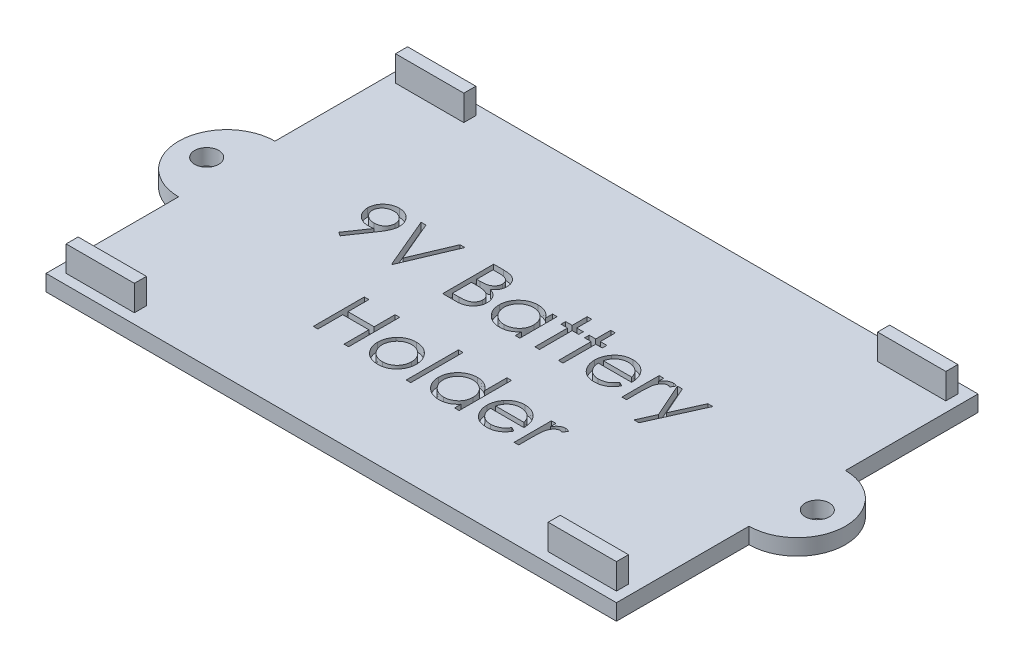
from build123d import *

# Parameters (mm, degrees)
SKETCH1_W               = 71
SKETCH1_H               = 45
BOSS_EXTRUDE1_DEPTH     = 2
SKETCH2_W               = 8.5
SKETCH2_H               = 1.5
BOSS_EXTRUDE2_DEPTH     = 3.175
MIRROR2_COPY_1_SKETCH_W = 8.5
MIRROR2_COPY_1_SKETCH_H = 1.5
MIRROR2_COPY_1_DEPTH    = 3.175
SKETCH3_W               = 0.569871795
SKETCH3_H               = 6.512820512
CUT_EXTRUDE1_DEPTH      = 1
BOSS_EXTRUDE3_DEPTH     = 2
SKETCH5_R               = 1.5
CUT_EXTRUDE2_DEPTH      = 2


with BuildPart() as part:
    # Sketch1 → Boss-Extrude1 (new body)
    with BuildSketch(Plane(origin=(0, 0, 0), x_dir=(1, 0, 0), z_dir=(0, 1, 0))):
        Rectangle(SKETCH1_W, SKETCH1_H)
    extrude(amount=BOSS_EXTRUDE1_DEPTH)

    # Sketch2 → Boss-Extrude2 (add)
    with BuildSketch(Plane(origin=(0, 2, 0), x_dir=(1, 0, 0), z_dir=(0, 1, 0))):
        with Locations((-30, -20.5)):
            Rectangle(SKETCH2_W, SKETCH2_H)
    boss_extrude2 = extrude(amount=BOSS_EXTRUDE2_DEPTH)

    # Mirror1: Boss-Extrude2 across plane
    add(boss_extrude2.mirror(Plane.XY))

    # Mirror2: Boss-Extrude2 across plane
    add(boss_extrude2.mirror(Plane(origin=(0, 0, 0), x_dir=(0, 0, 1), z_dir=(1, 0, 0))))

    # Mirror2 copy 1 sketch → Mirror2 copy 1 (add)
    with BuildSketch(Plane(origin=(0, 2, 0), x_dir=(-1, 0, 0), z_dir=(0, 1, 0))):
        with Locations((-30, -20.5)):
            Rectangle(MIRROR2_COPY_1_SKETCH_W, MIRROR2_COPY_1_SKETCH_H)
    extrude(amount=MIRROR2_COPY_1_DEPTH)

    # Sketch3 → Cut-Extrude1 (cut)
    with BuildSketch(Plane(origin=(0, 2, 0), x_dir=(1, 0, 0), z_dir=(0, 1, 0))):
        with BuildLine():
            Line((-21.248076923, -0.162820513), (-21.703465545, 0.153916266))
            Line((-21.703465545, 0.153916266), (-19.937880609, 2.734875801))
            add(Edge.make_bspline(
                [(-19.937880609, 2.734875801), (-20.050530944, 2.721099815), (-20.272345733, 2.69397413), (-20.495751618, 2.688990913), (-20.605699119, 2.686538462)],
                knots=[0, 0, 0, 0, 0.000340231, 0.000669933, 0.000669933, 0.000669933, 0.000669933], degree=3))
            add(Edge.make_bspline(
                [(-20.605699119, 2.686538462), (-20.672359691, 2.688245843), (-20.803208565, 2.691597284), (-20.995580278, 2.718161707), (-21.180429795, 2.759074082), (-21.357267055, 2.820122538), (-21.526756728, 2.895992717), (-21.688528808, 2.990076156), (-21.842365524, 3.100758999), (-21.986614682, 3.227455998), (-22.117808837, 3.366571893), (-22.234691105, 3.513811417), (-22.331830016, 3.670884964), (-22.41252325, 3.834588362), (-22.47371993, 4.007274527), (-22.518283391, 4.186978439), (-22.545719662, 4.374959561), (-22.548983736, 4.502912298), (-22.550641026, 4.567878606)],
                knots=[0, 0, 0, 0, 0.000199908, 0.000392402, 0.000581563, 0.000767006, 0.000952605, 0.001137838, 0.00132741, 0.001520307, 0.001712868, 0.00190041, 0.002083247, 0.002265863, 0.002446921, 0.002631721, 0.002820609, 0.003015434, 0.003015434, 0.003015434, 0.003015434], degree=3))
            add(Edge.make_bspline(
                [(-22.550641026, 4.567878606), (-22.547494265, 4.656721733), (-22.541317813, 4.831102769), (-22.491609075, 5.08588975), (-22.409856745, 5.326802479), (-22.295868119, 5.553207545), (-22.152295124, 5.761848115), (-21.979740968, 5.949823734), (-21.779255204, 6.114460826), (-21.555404969, 6.255982509), (-21.313464489, 6.369801719), (-21.060065638, 6.453693021), (-20.79715002, 6.503039321), (-20.619045818, 6.509545097), (-20.529377003, 6.512820513)],
                knots=[0, 0, 0, 0, 0.000266369, 0.000522829, 0.000775449, 0.001027459, 0.001280799, 0.00153288, 0.001790375, 0.002056814, 0.002325395, 0.002590482, 0.002855691, 0.0031246, 0.0031246, 0.0031246, 0.0031246], degree=3))
            add(Edge.make_bspline(
                [(-20.529377003, 6.512820513), (-20.441405156, 6.509500074), (-20.267581078, 6.5029392), (-20.011968167, 6.454889713), (-19.767146607, 6.373906036), (-19.53447356, 6.261992613), (-19.319046341, 6.121710395), (-19.125324512, 5.954552044), (-18.957728891, 5.760413445), (-18.816534136, 5.543990042), (-18.703195634, 5.311458519), (-18.621421635, 5.068736259), (-18.571083118, 4.817568865), (-18.564739782, 4.64739889), (-18.561538462, 4.561518429)],
                knots=[0, 0, 0, 0, 0.00026383, 0.000521303, 0.000777137, 0.001035436, 0.001293696, 0.001546188, 0.001800474, 0.002060496, 0.002319348, 0.002574378, 0.002827091, 0.003084573, 0.003084573, 0.003084573, 0.003084573], degree=3))
            add(Edge.make_bspline(
                [(-18.561538462, 4.561518429), (-18.563676432, 4.494854738), (-18.56801277, 4.359644114), (-18.598377213, 4.15421192), (-18.649939549, 3.944750404), (-18.708453345, 3.767455509), (-18.764935993, 3.621027322), (-18.818096617, 3.505363741), (-18.877082953, 3.383622877), (-18.945878427, 3.257081278), (-19.01983288, 3.124125822), (-19.103397567, 2.986090038), (-19.194666248, 2.842788693), (-19.259671596, 2.746183262), (-19.292958734, 2.696714744)],
                knots=[0, 0, 0, 0, 0.000199969, 0.000405586, 0.000621552, 0.000846414, 0.000965232, 0.001092194, 0.001228159, 0.001371001, 0.001524206, 0.001684548, 0.001854987, 0.002033856, 0.002033856, 0.002033856, 0.002033856], degree=3))
            Line((-19.292958734, 2.696714744), (-21.248076923, -0.162820513))
        make_face()
        with BuildLine():
            add(Edge.make_bspline(
                [(-20.500120192, 3.337820513), (-20.449621338, 3.339200066), (-20.351317237, 3.341885588), (-20.207304137, 3.358230927), (-20.071370225, 3.387212301), (-19.943152387, 3.428795208), (-19.821365008, 3.478972307), (-19.707942527, 3.54285691), (-19.602790019, 3.619087091), (-19.505203351, 3.704739548), (-19.418545809, 3.799899892), (-19.341360596, 3.899498928), (-19.275754995, 4.003973864), (-19.223933049, 4.114633068), (-19.18132532, 4.228782861), (-19.151901212, 4.348261477), (-19.135601065, 4.472446432), (-19.13282235, 4.556808283), (-19.131410256, 4.599679487)],
                knots=[0, 0, 0, 0, 0.000151506, 0.00029493, 0.000434147, 0.000567705, 0.000698823, 0.000828676, 0.000957177, 0.001087851, 0.001217486, 0.001342663, 0.001465499, 0.00158669, 0.001708626, 0.00183049, 0.00195498, 0.002083613, 0.002083613, 0.002083613, 0.002083613], degree=3))
            add(Edge.make_bspline(
                [(-19.131410256, 4.599679487), (-19.132625228, 4.642568594), (-19.135019477, 4.72708684), (-19.154227864, 4.851455654), (-19.18801934, 4.970641998), (-19.23335922, 5.085298378), (-19.293085937, 5.194482767), (-19.364756547, 5.299565963), (-19.44990542, 5.399881681), (-19.547881504, 5.493070623), (-19.653535622, 5.57897324), (-19.766131101, 5.65478512), (-19.884739877, 5.718323577), (-20.008638337, 5.770754565), (-20.138084627, 5.811669929), (-20.273002149, 5.841092862), (-20.41407267, 5.857370189), (-20.509833004, 5.86013134), (-20.558633814, 5.861538462)],
                knots=[0, 0, 0, 0, 0.000128633, 0.000253487, 0.000376322, 0.000499624, 0.000622565, 0.000748875, 0.00088064, 0.001016486, 0.00115396, 0.00128873, 0.001423042, 0.001556999, 0.001691769, 0.001829742, 0.00197064, 0.002117062, 0.002117062, 0.002117062, 0.002117062], degree=3))
            add(Edge.make_bspline(
                [(-20.558633814, 5.861538462), (-20.607010207, 5.860129067), (-20.70192429, 5.857363846), (-20.841740694, 5.841123803), (-20.975745956, 5.811472053), (-21.104817181, 5.770773517), (-21.22871196, 5.718319666), (-21.347315142, 5.654781791), (-21.459936958, 5.578990691), (-21.56548978, 5.493003032), (-21.663638867, 5.400315446), (-21.747323755, 5.29912651), (-21.819158388, 5.19453743), (-21.878803036, 5.085283851), (-21.924164746, 4.970645876), (-21.957950377, 4.851454604), (-21.977160334, 4.727087114), (-21.979554369, 4.642568686), (-21.980769231, 4.599679487)],
                knots=[0, 0, 0, 0, 0.000145151, 0.000284786, 0.000421516, 0.000556286, 0.000690243, 0.000824556, 0.000959325, 0.001096799, 0.001232645, 0.001363591, 0.001489901, 0.001612842, 0.001736144, 0.001858979, 0.001983833, 0.002112466, 0.002112466, 0.002112466, 0.002112466], degree=3))
            add(Edge.make_bspline(
                [(-21.980769231, 4.599679487), (-21.979669908, 4.556774898), (-21.977501841, 4.472159196), (-21.956587137, 4.34783274), (-21.921610829, 4.228655588), (-21.874767078, 4.113468934), (-21.813078479, 4.003392848), (-21.737379497, 3.898949206), (-21.648650864, 3.798954032), (-21.548078679, 3.704960948), (-21.438009301, 3.618687715), (-21.320449491, 3.543339736), (-21.197423072, 3.479708301), (-21.068496971, 3.42865179), (-20.934626634, 3.387627772), (-20.794608895, 3.35828434), (-20.648906807, 3.342042371), (-20.550191555, 3.3392413), (-20.500120192, 3.337820513)],
                knots=[0, 0, 0, 0, 0.000128633, 0.000253688, 0.000376872, 0.000500652, 0.000625933, 0.000754433, 0.000886902, 0.001026392, 0.001166853, 0.001305877, 0.001444692, 0.001581695, 0.001721324, 0.001864273, 0.002010225, 0.00216046, 0.00216046, 0.00216046, 0.00216046], degree=3))
        make_face(mode=Mode.SUBTRACT)
        Polygon((-17.666025641, 6.35), (-17.055448718, 6.35), (-14.938782051, 1.345813301), (-12.822115385, 6.35), (-12.211538462, 6.35), (-14.898076923, 0), (-14.979487179, 0), align=None)
        with BuildLine():
            Line((-8.629487179, 6.35), (-7.39052484, 6.35))
            add(Edge.make_bspline(
                [(-7.39052484, 6.35), (-7.329876029, 6.349681139), (-7.212323541, 6.349063106), (-7.041382553, 6.339477996), (-6.881273997, 6.326408481), (-6.731951438, 6.305671027), (-6.593483878, 6.280648803), (-6.465454022, 6.250346937), (-6.348268995, 6.214012938), (-6.208364459, 6.156234684), (-6.04885126, 6.070376936), (-5.876134176, 5.943506539), (-5.728443628, 5.788326213), (-5.601105595, 5.61327911), (-5.499866421, 5.420718496), (-5.426624982, 5.215233967), (-5.380255693, 4.99947595), (-5.375486963, 4.851351899), (-5.373076923, 4.776492388)],
                knots=[0, 0, 0, 0, 0.000181919, 0.000352604, 0.00051349, 0.000663703, 0.00080467, 0.000935486, 0.001058189, 0.001172283, 0.001389131, 0.001600035, 0.00181234, 0.002029124, 0.002247618, 0.002462475, 0.002682011, 0.002906326, 0.002906326, 0.002906326, 0.002906326], degree=3))
            add(Edge.make_bspline(
                [(-5.373076923, 4.776492388), (-5.375060334, 4.706365608), (-5.378957923, 4.568559873), (-5.416228357, 4.367003418), (-5.474576999, 4.175140492), (-5.555685094, 3.993671307), (-5.661098715, 3.826696038), (-5.786027379, 3.672867712), (-5.936752435, 3.538699366), (-6.049679456, 3.463691528), (-6.107041266, 3.425590946)],
                knots=[0, 0, 0, 0, 0.000210198, 0.000413059, 0.000612634, 0.000810762, 0.001007352, 0.001203448, 0.00140342, 0.001609859, 0.001609859, 0.001609859, 0.001609859], degree=3))
            add(Edge.make_bspline(
                [(-6.107041266, 3.425590946), (-6.03490449, 3.397895876), (-5.896888969, 3.344908347), (-5.706958632, 3.251226863), (-5.543319413, 3.149332748), (-5.404713162, 3.038059249), (-5.286171988, 2.918118978), (-5.182661652, 2.78775327), (-5.09433973, 2.645261524), (-5.018660569, 2.492129396), (-4.959607826, 2.329920517), (-4.91538297, 2.160156395), (-4.890042027, 1.983445773), (-4.886435878, 1.863185156), (-4.884615385, 1.802473958)],
                knots=[0, 0, 0, 0, 0.000231723, 0.000443344, 0.000634273, 0.000808894, 0.000975297, 0.001139193, 0.001307198, 0.001477294, 0.001650744, 0.001824133, 0.002002767, 0.002184886, 0.002184886, 0.002184886, 0.002184886], degree=3))
            add(Edge.make_bspline(
                [(-4.884615385, 1.802473958), (-4.886387662, 1.74048549), (-4.889874669, 1.618521443), (-4.915601189, 1.439351413), (-4.959160569, 1.268128296), (-5.019161077, 1.103744607), (-5.097469848, 0.946518363), (-5.192770583, 0.796271441), (-5.306402134, 0.654513441), (-5.433516197, 0.519669154), (-5.577320375, 0.398424454), (-5.732470387, 0.290445958), (-5.900920139, 0.201643816), (-6.079903043, 0.127047606), (-6.271426873, 0.070065974), (-6.474631604, 0.030201447), (-6.68934198, 0.00334088), (-6.836679671, 0.001132523), (-6.912239583, 0)],
                knots=[0, 0, 0, 0, 0.00018593, 0.000365823, 0.000541677, 0.000715127, 0.000889772, 0.001067625, 0.00124781, 0.001434053, 0.001622662, 0.001811078, 0.002000013, 0.002192776, 0.002391982, 0.002598291, 0.002813502, 0.003040053, 0.003040053, 0.003040053, 0.003040053], degree=3))
            Line((-6.912239583, 0), (-8.629487179, 0))
            Line((-8.629487179, 0), (-8.629487179, 6.35))
        make_face()
        with BuildLine():
            Line((-8.059615385, 5.698717949), (-8.059615385, 3.663461538))
            Line((-8.059615385, 3.663461538), (-7.676732772, 3.663461538))
            add(Edge.make_bspline(
                [(-7.676732772, 3.663461538), (-7.620764244, 3.664187113), (-7.51262164, 3.665589071), (-7.356012685, 3.669605023), (-7.210643009, 3.680850045), (-7.076763541, 3.692091835), (-6.954585107, 3.710370015), (-6.844378387, 3.732127153), (-6.744413789, 3.755137566), (-6.6291349, 3.794270778), (-6.498373979, 3.852105989), (-6.358976776, 3.941862034), (-6.236087095, 4.048767646), (-6.132315054, 4.172122677), (-6.047385672, 4.307951329), (-5.988396503, 4.454086383), (-5.948396431, 4.606885765), (-5.944783224, 4.711784596), (-5.942948718, 4.765044071)],
                knots=[0, 0, 0, 0, 0.000167928, 0.000324471, 0.00046984, 0.000605274, 0.000727423, 0.000840183, 0.000942303, 0.001034821, 0.00120505, 0.001369832, 0.0015303, 0.001691868, 0.001851786, 0.002008639, 0.002163205, 0.002322621, 0.002322621, 0.002322621, 0.002322621], degree=3))
            add(Edge.make_bspline(
                [(-5.942948718, 4.765044071), (-5.943903359, 4.80028797), (-5.945775992, 4.869422728), (-5.961112698, 4.970205128), (-5.987179583, 5.064990222), (-6.020660944, 5.155076965), (-6.067448993, 5.237648464), (-6.122536991, 5.315559691), (-6.189095315, 5.386157392), (-6.264855011, 5.452142053), (-6.351956369, 5.510642839), (-6.450347427, 5.561879652), (-6.561359356, 5.603137918), (-6.68312125, 5.639271509), (-6.817507366, 5.664650271), (-6.962966913, 5.685792846), (-7.120691331, 5.696556535), (-7.229811732, 5.697981407), (-7.286217949, 5.698717949)],
                knots=[0, 0, 0, 0, 0.000105701, 0.000207345, 0.000304853, 0.000400289, 0.000494806, 0.000588704, 0.000685913, 0.000785116, 0.000889546, 0.000999921, 0.001117093, 0.001244297, 0.001380505, 0.001526939, 0.001685086, 0.00185431, 0.00185431, 0.00185431, 0.00185431], degree=3))
            Line((-7.286217949, 5.698717949), (-8.059615385, 5.698717949))
        make_face(mode=Mode.SUBTRACT)
        with BuildLine():
            Line((-8.059615385, 3.012179487), (-8.059615385, 0.651282051))
            Line((-8.059615385, 0.651282051), (-7.248056891, 0.651282051))
            add(Edge.make_bspline(
                [(-7.248056891, 0.651282051), (-7.189965411, 0.651978279), (-7.078001742, 0.653320165), (-6.916346653, 0.657700857), (-6.766517308, 0.667665414), (-6.629197404, 0.683351456), (-6.502904154, 0.700366642), (-6.389152608, 0.723247109), (-6.287020671, 0.749461652), (-6.168594427, 0.789982221), (-6.035238062, 0.852931533), (-5.891526937, 0.947844487), (-5.763753655, 1.060916774), (-5.655249828, 1.191782861), (-5.566326263, 1.334079697), (-5.50163708, 1.484929117), (-5.461739383, 1.641838574), (-5.456909447, 1.748821038), (-5.454487179, 1.802473958)],
                knots=[0, 0, 0, 0, 0.000174287, 0.000335916, 0.000485092, 0.000624581, 0.000750506, 0.000867257, 0.000972467, 0.001066598, 0.001242424, 0.00141318, 0.001581671, 0.001752356, 0.001921441, 0.00208329, 0.002243101, 0.002403882, 0.002403882, 0.002403882, 0.002403882], degree=3))
            add(Edge.make_bspline(
                [(-5.454487179, 1.802473958), (-5.454988112, 1.836026162), (-5.455981896, 1.902589369), (-5.470969012, 2.000408069), (-5.492765604, 2.095160725), (-5.520944062, 2.187104626), (-5.561982238, 2.274577466), (-5.609891256, 2.359309252), (-5.666064085, 2.441411994), (-5.753592786, 2.545211368), (-5.880904815, 2.664803663), (-6.061801393, 2.781893131), (-6.267491133, 2.876322724), (-6.416675299, 2.916417488), (-6.493739984, 2.937129407)],
                knots=[0, 0, 0, 0, 0.000100563, 0.000199504, 0.000296087, 0.000392233, 0.000487296, 0.000585276, 0.000684069, 0.00078521, 0.000992212, 0.001205307, 0.001429016, 0.001668064, 0.001668064, 0.001668064, 0.001668064], degree=3))
            add(Edge.make_bspline(
                [(-6.493739984, 2.937129407), (-6.524635629, 2.943397917), (-6.591623761, 2.956989338), (-6.700857514, 2.971336171), (-6.825564019, 2.984117923), (-6.966031239, 2.993572452), (-7.122436894, 3.003345181), (-7.295115018, 3.007145785), (-7.483360432, 3.011680157), (-7.613975164, 3.012008786), (-7.681820913, 3.012179487)],
                knots=[0, 0, 0, 0, 9.4551e-05, 0.000205006, 0.000330312, 0.000470606, 0.000627319, 0.000800391, 0.000988691, 0.001192221, 0.001192221, 0.001192221, 0.001192221], degree=3))
            Line((-7.681820913, 3.012179487), (-8.059615385, 3.012179487))
        make_face(mode=Mode.SUBTRACT)
        with BuildLine():
            Line((0.976923077, 4.640384615), (0.976923077, 0))
            Line((0.976923077, 0), (0.407051282, 0))
            Line((0.407051282, 0), (0.407051282, 0.802654247))
            add(Edge.make_bspline(
                [(0.407051282, 0.802654247), (0.342791476, 0.730010983), (0.217387657, 0.588246742), (0.007944486, 0.403040514), (-0.214066351, 0.249954131), (-0.44756732, 0.126310713), (-0.692347561, 0.033433696), (-0.947864462, -0.032581193), (-1.214222253, -0.075024294), (-1.396108668, -0.079262505), (-1.48828125, -0.081410256)],
                knots=[0, 0, 0, 0, 0.000290762, 0.000567426, 0.000836293, 0.001098035, 0.001358135, 0.001619769, 0.001888723, 0.002165047, 0.002165047, 0.002165047, 0.002165047], degree=3))
            add(Edge.make_bspline(
                [(-1.48828125, -0.081410256), (-1.570228823, -0.079185267), (-1.731833067, -0.074797489), (-1.969557249, -0.040757309), (-2.198324616, 0.013908247), (-2.418351341, 0.089928433), (-2.628213662, 0.190767923), (-2.829708409, 0.311492759), (-3.021791721, 0.455258265), (-3.201535799, 0.619610831), (-3.367056714, 0.79812745), (-3.512310737, 0.988528657), (-3.633419897, 1.189991122), (-3.734693472, 1.39996413), (-3.812701125, 1.620064056), (-3.867081861, 1.849529775), (-3.901082386, 2.088089974), (-3.905468351, 2.250540251), (-3.907692308, 2.33291266)],
                knots=[0, 0, 0, 0, 0.00024577, 0.000484669, 0.00071884, 0.00095056, 0.001181567, 0.001416081, 0.001654206, 0.001900039, 0.002145792, 0.002383666, 0.00261709, 0.002849793, 0.003081935, 0.003316107, 0.003556266, 0.003803306, 0.003803306, 0.003803306, 0.003803306], degree=3))
            add(Edge.make_bspline(
                [(-3.907692308, 2.33291266), (-3.90541906, 2.413582522), (-3.900924971, 2.573062488), (-3.867445558, 2.807610983), (-3.811146442, 3.033522685), (-3.732138204, 3.250070282), (-3.630824943, 3.457515801), (-3.507583985, 3.656005961), (-3.36240643, 3.846087582), (-3.195034206, 4.023291094), (-3.01372398, 4.186977065), (-2.819760997, 4.329233476), (-2.617970187, 4.452091188), (-2.405221582, 4.549433923), (-2.18466412, 4.628190441), (-1.954334297, 4.682678826), (-1.715190433, 4.714786824), (-1.552829112, 4.71943641), (-1.470472756, 4.721794872)],
                knots=[0, 0, 0, 0, 0.000241958, 0.000478337, 0.000709106, 0.000939284, 0.001168551, 0.00140047, 0.001639115, 0.001884802, 0.002130726, 0.002370895, 0.002605409, 0.002838177, 0.003071519, 0.003306928, 0.003546915, 0.003793955, 0.003793955, 0.003793955, 0.003793955], degree=3))
            add(Edge.make_bspline(
                [(-1.470472756, 4.721794872), (-1.375767298, 4.71918638), (-1.190054363, 4.71407125), (-0.918404975, 4.671503159), (-0.661421422, 4.599587654), (-0.417119955, 4.501765908), (-0.186377853, 4.371774642), (0.028620418, 4.20779957), (0.230124938, 4.010874845), (0.346929182, 3.859617039), (0.407051282, 3.781760817)],
                knots=[0, 0, 0, 0, 0.000284009, 0.000556928, 0.000822345, 0.001083124, 0.001344564, 0.001614238, 0.001892186, 0.002187002, 0.002187002, 0.002187002, 0.002187002], degree=3))
            Line((0.407051282, 3.781760817), (0.407051282, 4.640384615))
            Line((0.407051282, 4.640384615), (0.976923077, 4.640384615))
        make_face()
        with BuildLine():
            add(Edge.make_bspline(
                [(-1.462840545, 4.151923077), (-1.546142272, 4.148959191), (-1.710566632, 4.143108953), (-1.951946464, 4.09743704), (-2.182929373, 4.021446419), (-2.402360108, 3.917520684), (-2.606772443, 3.786839976), (-2.789459532, 3.628776895), (-2.951915576, 3.447644026), (-3.088546284, 3.244258769), (-3.199926185, 3.026221375), (-3.278243515, 2.798302752), (-3.329894864, 2.564613721), (-3.335171751, 2.406112848), (-3.337820513, 2.326552484)],
                knots=[0, 0, 0, 0, 0.000249786, 0.000493037, 0.00073399, 0.000977521, 0.001219572, 0.001459505, 0.001700041, 0.001947359, 0.002192545, 0.00243231, 0.002668812, 0.002907172, 0.002907172, 0.002907172, 0.002907172], degree=3))
            add(Edge.make_bspline(
                [(-3.337820513, 2.326552484), (-3.334437064, 2.247467575), (-3.327683427, 2.089607744), (-3.279150024, 1.855600126), (-3.197725111, 1.627627793), (-3.086614511, 1.407625704), (-2.947483064, 1.203365979), (-2.786213651, 1.018780328), (-2.601246712, 0.860049218), (-2.396363949, 0.727175335), (-2.177546632, 0.619837618), (-1.947433642, 0.545151387), (-1.710350698, 0.496931699), (-1.549147178, 0.491299291), (-1.467928686, 0.488461538)],
                knots=[0, 0, 0, 0, 0.000237176, 0.000473422, 0.000713608, 0.000961638, 0.001210723, 0.001453162, 0.001694889, 0.001939391, 0.002184022, 0.002423766, 0.002663507, 0.002906945, 0.002906945, 0.002906945, 0.002906945], degree=3))
            add(Edge.make_bspline(
                [(-1.467928686, 0.488461538), (-1.385475745, 0.491473187), (-1.221485024, 0.497463058), (-0.979389082, 0.543330497), (-0.744448221, 0.619111031), (-0.519862821, 0.724156589), (-0.310646412, 0.854344935), (-0.122871691, 1.0067578), (0.03590728, 1.184019291), (0.170513872, 1.378830856), (0.276060699, 1.59239405), (0.352942978, 1.819786081), (0.398397921, 2.061014867), (0.404126945, 2.225867992), (0.407051282, 2.310016026)],
                knots=[0, 0, 0, 0, 0.000247246, 0.000491749, 0.00073633, 0.000986158, 0.001233581, 0.001473979, 0.001709031, 0.001945074, 0.002182295, 0.002421234, 0.002663235, 0.00291556, 0.00291556, 0.00291556, 0.00291556], degree=3))
            add(Edge.make_bspline(
                [(0.407051282, 2.310016026), (0.405310191, 2.374128947), (0.401883173, 2.500323464), (0.375701997, 2.685611961), (0.334055202, 2.862928863), (0.275370008, 3.032460599), (0.198278678, 3.193269842), (0.105300588, 3.346511235), (-0.005199299, 3.491387776), (-0.131442191, 3.62590449), (-0.26962763, 3.748598215), (-0.415849153, 3.858116194), (-0.571839166, 3.948084396), (-0.734974361, 4.022544989), (-0.905537782, 4.081798018), (-1.084917335, 4.121327119), (-1.271206354, 4.148469416), (-1.398289912, 4.150759736), (-1.462840545, 4.151923077)],
                knots=[0, 0, 0, 0, 0.000192284, 0.000378475, 0.000560202, 0.000738015, 0.000915535, 0.001094205, 0.001274839, 0.001461134, 0.001646738, 0.001828644, 0.002008199, 0.002185797, 0.002366014, 0.002548692, 0.002736143, 0.002929643, 0.002929643, 0.002929643, 0.002929643], degree=3))
        make_face(mode=Mode.SUBTRACT)
        Polygon((2.849358974, 6.512820513), (3.419230769, 6.512820513), (3.419230769, 4.640384615), (4.233333333, 4.640384615), (4.233333333, 4.070512821), (3.419230769, 4.070512821), (3.419230769, 0), (2.849358974, 0), (2.849358974, 4.070512821), (2.03525641, 4.070512821), (2.03525641, 4.640384615), (2.849358974, 4.640384615), align=None)
        Polygon((5.780128205, 6.512820513), (6.35, 6.512820513), (6.35, 4.640384615), (7.164102564, 4.640384615), (7.164102564, 4.070512821), (6.35, 4.070512821), (6.35, 0), (5.780128205, 0), (5.780128205, 4.070512821), (4.966025641, 4.070512821), (4.966025641, 4.640384615), (5.780128205, 4.640384615), align=None)
        with BuildLine():
            Line((11.949499199, 1.465384615), (12.455769231, 1.199529247))
            add(Edge.make_bspline(
                [(12.455769231, 1.199529247), (12.415425694, 1.127967774), (12.336933147, 0.988737488), (12.201948933, 0.79745397), (12.06044903, 0.625373114), (11.906046116, 0.477092169), (11.743359699, 0.3478218), (11.571487597, 0.234723175), (11.389535027, 0.138351002), (11.197493384, 0.05715713), (10.993749912, -0.005271524), (10.777810875, -0.049366324), (10.549262591, -0.076622826), (10.39260595, -0.07978901), (10.312389824, -0.081410256)],
                knots=[0, 0, 0, 0, 0.000246306, 0.000479213, 0.000701365, 0.000913669, 0.001120076, 0.001323999, 0.001529994, 0.001736945, 0.001948585, 0.002168121, 0.002397377, 0.002637956, 0.002637956, 0.002637956, 0.002637956], degree=3))
            add(Edge.make_bspline(
                [(10.312389824, -0.081410256), (10.223232236, -0.079328953), (10.049311611, -0.075268932), (9.796146641, -0.040266889), (9.557786839, 0.016832962), (9.334245606, 0.096599015), (9.126070377, 0.200788589), (8.932847397, 0.327715078), (8.753560543, 0.476726454), (8.593859478, 0.64911343), (8.450088433, 0.833593552), (8.323223017, 1.0258278), (8.217164535, 1.225332507), (8.130890514, 1.430837601), (8.061213116, 1.641047808), (8.012650668, 1.857875756), (7.984656696, 2.080734602), (7.980366917, 2.231496911), (7.978205128, 2.307471955)],
                knots=[0, 0, 0, 0, 0.000267373, 0.000521567, 0.000764991, 0.001001583, 0.001231976, 0.001461655, 0.001693741, 0.001929511, 0.002165136, 0.002394815, 0.002619591, 0.002841906, 0.003062747, 0.003283088, 0.003507446, 0.003735368, 0.003735368, 0.003735368, 0.003735368], degree=3))
            add(Edge.make_bspline(
                [(7.978205128, 2.307471955), (7.980126713, 2.378764005), (7.983935041, 2.520055432), (8.007939469, 2.729180063), (8.050481373, 2.932431684), (8.108858417, 3.129979182), (8.18424425, 3.321491797), (8.276468419, 3.507086084), (8.38567459, 3.686564552), (8.469989298, 3.799781666), (8.512459936, 3.856810897)],
                knots=[0, 0, 0, 0, 0.000213887, 0.000423896, 0.00063046, 0.000836125, 0.00104116, 0.001247092, 0.001457178, 0.00167041, 0.00167041, 0.00167041, 0.00167041], degree=3))
            add(Edge.make_bspline(
                [(8.512459936, 3.856810897), (8.569986732, 3.925515847), (8.683218021, 4.060749349), (8.874727408, 4.238437454), (9.082100622, 4.387288304), (9.302738857, 4.510672679), (9.53920646, 4.604423439), (9.788324746, 4.674287195), (10.052930309, 4.713435872), (10.233824067, 4.718965513), (10.326382212, 4.721794872)],
                knots=[0, 0, 0, 0, 0.000268643, 0.000528777, 0.000781195, 0.001032868, 0.001285142, 0.001542524, 0.001807514, 0.002085171, 0.002085171, 0.002085171, 0.002085171], degree=3))
            add(Edge.make_bspline(
                [(10.326382212, 4.721794872), (10.421537153, 4.71933824), (10.608209456, 4.714518889), (10.88041059, 4.669839684), (11.13796789, 4.598987192), (11.380778291, 4.498922458), (11.608866409, 4.3698187), (11.820749671, 4.209904216), (12.020051701, 4.024088544), (12.136000122, 3.881189578), (12.195002003, 3.808473558)],
                knots=[0, 0, 0, 0, 0.000285279, 0.000559653, 0.00082507, 0.001085153, 0.001345486, 0.001609052, 0.001879912, 0.002160548, 0.002160548, 0.002160548, 0.002160548], degree=3))
            add(Edge.make_bspline(
                [(12.195002003, 3.808473558), (12.235146591, 3.753675631), (12.315168553, 3.64444453), (12.415402577, 3.466334003), (12.502410994, 3.279987638), (12.571957938, 3.082393242), (12.628272461, 2.875892004), (12.669015547, 2.659007673), (12.692908997, 2.431804834), (12.697605634, 2.276998083), (12.7, 2.198076923)],
                knots=[0, 0, 0, 0, 0.000203625, 0.000405895, 0.000611921, 0.000819933, 0.001033468, 0.001253512, 0.00148122, 0.001718038, 0.001718038, 0.001718038, 0.001718038], degree=3))
            Line((12.7, 2.198076923), (8.548076923, 2.198076923))
            add(Edge.make_bspline(
                [(8.548076923, 2.198076923), (8.550870209, 2.136934652), (8.556363093, 2.016700843), (8.581971996, 1.840768136), (8.622337628, 1.673176501), (8.679068642, 1.515182982), (8.747769918, 1.364724036), (8.831926862, 1.222915769), (8.932328624, 1.090404096), (9.044316678, 0.966003718), (9.16897098, 0.855222051), (9.300112536, 0.756068114), (9.439619432, 0.672963675), (9.586391669, 0.605508732), (9.740191908, 0.552701558), (9.901068605, 0.516655655), (10.068705187, 0.492512761), (10.182979305, 0.489828226), (10.241155849, 0.488461538)],
                knots=[0, 0, 0, 0, 0.00018353, 0.000360905, 0.000532442, 0.00069981, 0.000863725, 0.001027995, 0.001193359, 0.001361754, 0.001529296, 0.00169288, 0.001854313, 0.002015385, 0.002176693, 0.00234116, 0.002509362, 0.002683798, 0.002683798, 0.002683798, 0.002683798], degree=3))
            add(Edge.make_bspline(
                [(10.241155849, 0.488461538), (10.298035789, 0.489564727), (10.410896499, 0.491753665), (10.578973483, 0.513038703), (10.744326626, 0.547456203), (10.906271553, 0.594428042), (11.061521516, 0.651717474), (11.205295585, 0.720846944), (11.337521119, 0.797318628), (11.461104759, 0.884784752), (11.580976418, 0.991842463), (11.699889215, 1.1254387), (11.827391143, 1.283440357), (11.907200833, 1.402358923), (11.949499199, 1.465384615)],
                knots=[0, 0, 0, 0, 0.000170571, 0.000338446, 0.00050734, 0.000676826, 0.00084387, 0.00100318, 0.001154808, 0.001301644, 0.001456613, 0.00163579, 0.001837627, 0.002065222, 0.002065222, 0.002065222, 0.002065222], degree=3))
        make_face()
        with BuildLine():
            add(Edge.make_bspline(
                [(12.130128205, 2.767948718), (12.109270043, 2.843537075), (12.069124796, 2.989020329), (11.985238821, 3.19048023), (11.890766169, 3.369528279), (11.778966742, 3.524794185), (11.652295625, 3.662686273), (11.505982222, 3.783188563), (11.341905673, 3.890988796), (11.160914089, 3.981979759), (10.969249707, 4.05943136), (10.768578473, 4.111365498), (10.563822201, 4.146942811), (10.425329996, 4.150255893), (10.355639022, 4.151923077)],
                knots=[0, 0, 0, 0, 0.000235027, 0.000452352, 0.000653261, 0.000841057, 0.001024689, 0.001213453, 0.001408203, 0.001612435, 0.001820303, 0.002027035, 0.00223323, 0.002442092, 0.002442092, 0.002442092, 0.002442092], degree=3))
            add(Edge.make_bspline(
                [(10.355639022, 4.151923077), (10.298762184, 4.15081333), (10.186328632, 4.148619594), (10.020682408, 4.127809502), (9.861606383, 4.093410926), (9.70792679, 4.046303076), (9.5616575, 3.983513183), (9.419789849, 3.909883615), (9.28593113, 3.820001027), (9.202217637, 3.751495676), (9.159925881, 3.716887019)],
                knots=[0, 0, 0, 0, 0.000170571, 0.000337184, 0.000499855, 0.000658375, 0.000818556, 0.000976739, 0.001137263, 0.001301158, 0.001301158, 0.001301158, 0.001301158], degree=3))
            add(Edge.make_bspline(
                [(9.159925881, 3.716887019), (9.129639498, 3.689501618), (9.068347241, 3.63408024), (8.986449437, 3.538595823), (8.908035151, 3.435632274), (8.836672667, 3.321250405), (8.771217617, 3.196752706), (8.709967373, 3.063189282), (8.65483774, 2.919546603), (8.623820511, 2.819448035), (8.60786258, 2.767948718)],
                knots=[0, 0, 0, 0, 0.00012238, 0.000247668, 0.000376652, 0.00051041, 0.000651531, 0.000798389, 0.000950996, 0.00111271, 0.00111271, 0.00111271, 0.00111271], degree=3))
            Line((8.60786258, 2.767948718), (12.130128205, 2.767948718))
        make_face(mode=Mode.SUBTRACT)
        with BuildLine():
            Line((13.676923077, 4.640384615), (14.246794872, 4.640384615))
            Line((14.246794872, 4.640384615), (14.246794872, 3.957301683))
            add(Edge.make_bspline(
                [(14.246794872, 3.957301683), (14.288865906, 4.020902971), (14.369326431, 4.142539941), (14.503062745, 4.303411387), (14.640047361, 4.436607258), (14.780936058, 4.542749356), (14.926764896, 4.622238872), (15.074333366, 4.680464807), (15.225963147, 4.714895079), (15.327856923, 4.71949186), (15.37890625, 4.721794872)],
                knots=[0, 0, 0, 0, 0.000228641, 0.000437274, 0.000626196, 0.00080072, 0.000964674, 0.001122945, 0.001275403, 0.001428476, 0.001428476, 0.001428476, 0.001428476], degree=3))
            add(Edge.make_bspline(
                [(15.37890625, 4.721794872), (15.418505442, 4.719634916), (15.499983354, 4.715190668), (15.623323196, 4.683965315), (15.75040203, 4.634112331), (15.832303218, 4.587230784), (15.875, 4.562790465)],
                knots=[0, 0, 0, 0, 0.000118736, 0.000244307, 0.000379658, 0.000527066, 0.000527066, 0.000527066, 0.000527066], degree=3))
            Line((15.875, 4.562790465), (15.562079327, 4.069240785))
            add(Edge.make_bspline(
                [(15.562079327, 4.069240785), (15.534667246, 4.081469554), (15.482633868, 4.104682097), (15.406516298, 4.13215403), (15.336337301, 4.148330049), (15.291626845, 4.150780636), (15.270783253, 4.151923077)],
                knots=[0, 0, 0, 0, 9.0027e-05, 0.000170889, 0.000242497, 0.000305034, 0.000305034, 0.000305034, 0.000305034], degree=3))
            add(Edge.make_bspline(
                [(15.270783253, 4.151923077), (15.225052851, 4.148875009), (15.131776086, 4.142657834), (14.994825637, 4.09378314), (14.861934279, 4.014815919), (14.756394263, 3.92723833), (14.674674747, 3.842787326), (14.616363195, 3.76903951), (14.562873068, 3.68634685), (14.51176424, 3.596122995), (14.465198249, 3.496827417), (14.421737635, 3.389452159), (14.382442269, 3.273872854), (14.360035398, 3.193350281), (14.348557692, 3.152103365)],
                knots=[0, 0, 0, 0, 0.000136961, 0.000279361, 0.000430989, 0.000599071, 0.000689036, 0.000783201, 0.000880576, 0.000984237, 0.001094053, 0.001209325, 0.001331612, 0.001460037, 0.001460037, 0.001460037, 0.001460037], degree=3))
            add(Edge.make_bspline(
                [(14.348557692, 3.152103365), (14.339971779, 3.115314779), (14.320954632, 3.033830856), (14.302464271, 2.897127104), (14.284195288, 2.735612751), (14.271319995, 2.548838219), (14.259385547, 2.337269928), (14.252654398, 2.100585569), (14.247024414, 1.838542203), (14.246873707, 1.655345877), (14.246794872, 1.559515224)],
                knots=[0, 0, 0, 0, 0.000113275, 0.000250896, 0.000413424, 0.000600936, 0.000812404, 0.001049125, 0.001311214, 0.001598697, 0.001598697, 0.001598697, 0.001598697], degree=3))
            Line((14.246794872, 1.559515224), (14.246794872, 0))
            Line((14.246794872, 0), (13.676923077, 0))
            Line((13.676923077, 0), (13.676923077, 4.640384615))
        make_face()
        Polygon((15.956410256, 4.640384615), (16.570803285, 4.640384615), (18.141766827, 1.086318109), (19.736899038, 4.640384615), (20.352564103, 4.640384615), (17.503205128, -1.709615385), (16.887540064, -1.709615385), (17.83266226, 0.395602965), align=None)
        Polygon((-13.14775641, -5.233333333), (-12.577884615, -5.233333333), (-12.577884615, -7.838461538), (-9.321474359, -7.838461538), (-9.321474359, -5.233333333), (-8.751602564, -5.233333333), (-8.751602564, -11.583333333), (-9.321474359, -11.583333333), (-9.321474359, -8.48974359), (-12.577884615, -8.48974359), (-12.577884615, -11.583333333), (-13.14775641, -11.583333333), align=None)
        with BuildLine():
            add(Edge.make_bspline(
                [(-5.044891827, -6.861538462), (-4.957821946, -6.863392464), (-4.787099189, -6.86702771), (-4.53707631, -6.905880576), (-4.298415849, -6.965293651), (-4.070203758, -7.0474292), (-3.855362765, -7.157523596), (-3.650763507, -7.288894738), (-3.456966934, -7.444528872), (-3.340810867, -7.564921368), (-3.281850962, -7.626031651)],
                knots=[0, 0, 0, 0, 0.000261018, 0.000511793, 0.000757062, 0.000998109, 0.001237606, 0.001479657, 0.001726593, 0.001981143, 0.001981143, 0.001981143, 0.001981143], degree=3))
            add(Edge.make_bspline(
                [(-3.281850962, -7.626031651), (-3.231083702, -7.684477025), (-3.130531669, -7.800236694), (-3.001598151, -7.987934735), (-2.890524749, -8.182317489), (-2.80151052, -8.38596621), (-2.731324834, -8.597103114), (-2.681494214, -8.816453905), (-2.651854346, -9.043534164), (-2.647857534, -9.197755413), (-2.645833333, -9.275861378)],
                knots=[0, 0, 0, 0, 0.000232086, 0.000459681, 0.000681833, 0.000902819, 0.001125265, 0.001348369, 0.001576673, 0.001810949, 0.001810949, 0.001810949, 0.001810949], degree=3))
            add(Edge.make_bspline(
                [(-2.645833333, -9.275861378), (-2.64761376, -9.354420054), (-2.651131965, -9.509655662), (-2.684412526, -9.738290797), (-2.736176068, -9.959987118), (-2.810256688, -10.173816462), (-2.905249258, -10.380432449), (-3.02116522, -10.578932632), (-3.158818011, -10.769708645), (-3.314853833, -10.951140551), (-3.487305095, -11.118356398), (-3.674387249, -11.26409483), (-3.872423853, -11.388956739), (-4.084048223, -11.489534236), (-4.307327806, -11.56883612), (-4.542744201, -11.624534722), (-4.789931686, -11.658210919), (-4.958709645, -11.662535402), (-5.044891827, -11.66474359)],
                knots=[0, 0, 0, 0, 0.000235546, 0.000465451, 0.000691608, 0.000917687, 0.001143082, 0.001372814, 0.001606155, 0.001847882, 0.00208988, 0.002325505, 0.002558096, 0.002790799, 0.003026963, 0.003267616, 0.003515337, 0.003773814, 0.003773814, 0.003773814, 0.003773814], degree=3))
            add(Edge.make_bspline(
                [(-5.044891827, -11.66474359), (-5.131496247, -11.662527991), (-5.301115378, -11.658188629), (-5.549175374, -11.624665559), (-5.785013682, -11.56886179), (-6.008585568, -11.489273625), (-6.22111979, -11.388953524), (-6.420303863, -11.264472316), (-6.607537996, -11.118313177), (-6.780025739, -10.951152263), (-6.93605178, -10.769705628), (-7.073707095, -10.578933415), (-7.189622401, -10.380432245), (-7.284615143, -10.173816517), (-7.358695718, -9.959987104), (-7.410459271, -9.738290801), (-7.443739829, -9.509655661), (-7.447258035, -9.354420054), (-7.449038462, -9.275861378)],
                knots=[0, 0, 0, 0, 0.000259748, 0.000508729, 0.000749382, 0.000985546, 0.001219397, 0.001453067, 0.001688693, 0.00193069, 0.002172417, 0.002405759, 0.00263549, 0.002860885, 0.003086964, 0.003313122, 0.003543026, 0.003778572, 0.003778572, 0.003778572, 0.003778572], degree=3))
            add(Edge.make_bspline(
                [(-7.449038462, -9.275861378), (-7.447000456, -9.198179931), (-7.442965554, -9.044384015), (-7.413355488, -8.817730633), (-7.363719249, -8.598751085), (-7.29344943, -8.38842915), (-7.203614727, -8.185672859), (-7.094102104, -7.990809808), (-6.963853385, -7.803960513), (-6.863701273, -7.688350453), (-6.813020833, -7.629847756)],
                knots=[0, 0, 0, 0, 0.000233005, 0.000461309, 0.000684413, 0.000905652, 0.001125475, 0.001348734, 0.001575285, 0.001807372, 0.001807372, 0.001807372, 0.001807372], degree=3))
            add(Edge.make_bspline(
                [(-6.813020833, -7.629847756), (-6.754149818, -7.568207509), (-6.638369608, -7.446981118), (-6.443608345, -7.291800681), (-6.239512412, -7.157695804), (-6.022297189, -7.049788956), (-5.794272575, -6.964810503), (-5.554389093, -6.905727354), (-5.3035178, -6.867167696), (-5.131959631, -6.863433573), (-5.044891827, -6.861538462)],
                knots=[0, 0, 0, 0, 0.000255448, 0.000502383, 0.000745126, 0.000986896, 0.001228382, 0.00147365, 0.001726942, 0.00198796, 0.00198796, 0.00198796, 0.00198796], degree=3))
        make_face()
        with BuildLine():
            add(Edge.make_bspline(
                [(-5.047435897, -7.431410256), (-5.109008421, -7.433160301), (-5.230563983, -7.436615214), (-5.409488087, -7.462893155), (-5.581736652, -7.504526484), (-5.747636469, -7.563679558), (-5.906628082, -7.640058989), (-6.058863712, -7.733872728), (-6.204791138, -7.843878235), (-6.341555739, -7.969903367), (-6.46707222, -8.107569543), (-6.576796549, -8.254251566), (-6.670096384, -8.407570222), (-6.747820673, -8.567684948), (-6.805709428, -8.736218328), (-6.847751912, -8.911261759), (-6.874005063, -9.093171872), (-6.877427492, -9.216835433), (-6.879166667, -9.279677484)],
                knots=[0, 0, 0, 0, 0.00018466, 0.000364553, 0.000541334, 0.000715547, 0.00089192, 0.001069504, 0.001251152, 0.001439314, 0.001626619, 0.001809283, 0.001987953, 0.002164326, 0.002342139, 0.002521392, 0.002703804, 0.002892275, 0.002892275, 0.002892275, 0.002892275], degree=3))
            add(Edge.make_bspline(
                [(-6.879166667, -9.279677484), (-6.876251429, -9.360870448), (-6.870465229, -9.522023298), (-6.8234113, -9.759352049), (-6.744696192, -9.987193409), (-6.638402127, -10.204211709), (-6.505222274, -10.405002842), (-6.348310024, -10.584021107), (-6.169349425, -10.738572508), (-5.970473774, -10.866807756), (-5.755745226, -10.968697598), (-5.528494472, -11.040904311), (-5.291474927, -11.087842953), (-5.129494172, -11.092508343), (-5.047435897, -11.094871795)],
                knots=[0, 0, 0, 0, 0.000243438, 0.000483178, 0.000722527, 0.000964873, 0.001206187, 0.00144324, 0.001676828, 0.001913224, 0.002151068, 0.002387605, 0.002627106, 0.002873007, 0.002873007, 0.002873007, 0.002873007], degree=3))
            add(Edge.make_bspline(
                [(-5.047435897, -11.094871795), (-4.965382342, -11.092494572), (-4.803410904, -11.087802), (-4.566720683, -11.041140713), (-4.340091048, -10.968381214), (-4.125585531, -10.866922348), (-3.926800408, -10.738085538), (-3.746552716, -10.584893826), (-3.590980236, -10.404528695), (-3.457932124, -10.20394575), (-3.34989732, -9.987529854), (-3.271550653, -9.759309997), (-3.224383605, -9.522034007), (-3.218612673, -9.360874036), (-3.215705128, -9.279677484)],
                knots=[0, 0, 0, 0, 0.000245901, 0.000485402, 0.000720729, 0.000958572, 0.001194969, 0.001429521, 0.001665736, 0.001907051, 0.002149959, 0.002389308, 0.002629049, 0.002872487, 0.002872487, 0.002872487, 0.002872487], degree=3))
            add(Edge.make_bspline(
                [(-3.215705128, -9.279677484), (-3.217443704, -9.216835058), (-3.220864955, -9.093170757), (-3.247126676, -8.91126602), (-3.289137441, -8.736202694), (-3.34714309, -8.567742631), (-3.424529658, -8.407155659), (-3.519628696, -8.254701726), (-3.628904985, -8.107061421), (-3.755936048, -7.970348387), (-3.89255789, -7.843829106), (-4.03854446, -7.733830071), (-4.190554349, -7.640471291), (-4.349084064, -7.563026254), (-4.515005151, -7.505064651), (-4.687012371, -7.462652763), (-4.865173069, -7.436726263), (-4.986293047, -7.433193592), (-5.047435897, -7.431410256)],
                knots=[0, 0, 0, 0, 0.000188472, 0.000370883, 0.000550137, 0.000727949, 0.000904322, 0.001083656, 0.001266321, 0.001454483, 0.001642645, 0.001824293, 0.002001877, 0.002177105, 0.002352516, 0.002528062, 0.002707955, 0.002891344, 0.002891344, 0.002891344, 0.002891344], degree=3))
        make_face(mode=Mode.SUBTRACT)
        with Locations((-1.302564103, -8.326923077)):
            Rectangle(SKETCH3_W, SKETCH3_H)
        with BuildLine():
            Line((5.006730769, -5.070512821), (5.006730769, -11.583333333))
            Line((5.006730769, -11.583333333), (4.436858974, -11.583333333))
            Line((4.436858974, -11.583333333), (4.436858974, -10.780679087))
            add(Edge.make_bspline(
                [(4.436858974, -10.780679087), (4.372599169, -10.85332235), (4.247195349, -10.995086592), (4.037752178, -11.180292819), (3.815741341, -11.333379202), (3.582240373, -11.457022621), (3.337460131, -11.549899637), (3.08194323, -11.615914526), (2.815585439, -11.658357627), (2.633699024, -11.662595838), (2.541526442, -11.66474359)],
                knots=[0, 0, 0, 0, 0.000290762, 0.000567426, 0.000836293, 0.001098035, 0.001358135, 0.001619769, 0.001888723, 0.002165047, 0.002165047, 0.002165047, 0.002165047], degree=3))
            add(Edge.make_bspline(
                [(2.541526442, -11.66474359), (2.459578869, -11.6625186), (2.297974626, -11.658130822), (2.060250443, -11.624090642), (1.831483076, -11.569425086), (1.611456351, -11.493404901), (1.40159403, -11.39256541), (1.200099284, -11.271840574), (1.008015971, -11.128075068), (0.828271893, -10.963722503), (0.662750978, -10.785205883), (0.517496955, -10.594804677), (0.396387796, -10.393342211), (0.295114221, -10.183369203), (0.217106567, -9.963269278), (0.162725831, -9.733803559), (0.128725306, -9.49524336), (0.124339342, -9.332793082), (0.122115385, -9.250420673)],
                knots=[0, 0, 0, 0, 0.00024577, 0.000484669, 0.00071884, 0.00095056, 0.001181567, 0.001416081, 0.001654206, 0.001900039, 0.002145792, 0.002383666, 0.00261709, 0.002849793, 0.003081935, 0.003316107, 0.003556266, 0.003803306, 0.003803306, 0.003803306, 0.003803306], degree=3))
            add(Edge.make_bspline(
                [(0.122115385, -9.250420673), (0.124388633, -9.169750811), (0.128882722, -9.010270845), (0.162362135, -8.77572235), (0.21866125, -8.549810649), (0.297669488, -8.333263052), (0.398982749, -8.125817532), (0.522223707, -7.927327372), (0.667401262, -7.737245751), (0.834773486, -7.56004224), (1.016083712, -7.396356268), (1.210046695, -7.254099857), (1.411837506, -7.131242146), (1.624586111, -7.03389941), (1.845143572, -6.955142892), (2.075473395, -6.900654507), (2.314617259, -6.86854651), (2.476978581, -6.863896923), (2.559334936, -6.861538462)],
                knots=[0, 0, 0, 0, 0.000241958, 0.000478337, 0.000709106, 0.000939284, 0.001168551, 0.00140047, 0.001639115, 0.001884802, 0.002130726, 0.002370895, 0.002605409, 0.002838177, 0.003071519, 0.003306928, 0.003546915, 0.003793955, 0.003793955, 0.003793955, 0.003793955], degree=3))
            add(Edge.make_bspline(
                [(2.559334936, -6.861538462), (2.654071144, -6.864381621), (2.840027793, -6.869962429), (3.111986539, -6.916601123), (3.369229775, -6.994910916), (3.613238481, -7.102119383), (3.842557955, -7.241457889), (4.058869146, -7.409735516), (4.258410317, -7.611714767), (4.376469195, -7.76341005), (4.436858974, -7.841005609)],
                knots=[0, 0, 0, 0, 0.000284074, 0.000557606, 0.0008248, 0.001089053, 0.001354982, 0.001627758, 0.001909292, 0.002204108, 0.002204108, 0.002204108, 0.002204108], degree=3))
            Line((4.436858974, -7.841005609), (4.436858974, -5.070512821))
            Line((4.436858974, -5.070512821), (5.006730769, -5.070512821))
        make_face()
        with BuildLine():
            add(Edge.make_bspline(
                [(2.566967147, -7.431410256), (2.48366542, -7.434374142), (2.31924106, -7.440224381), (2.077861228, -7.485896293), (1.846878319, -7.561886915), (1.627447585, -7.66581265), (1.423035249, -7.796493357), (1.24034816, -7.954556439), (1.077892116, -8.135689307), (0.941261409, -8.339074565), (0.829881507, -8.557111958), (0.751564178, -8.785030582), (0.699912829, -9.018719612), (0.694635941, -9.177220485), (0.691987179, -9.256780849)],
                knots=[0, 0, 0, 0, 0.000249786, 0.000493037, 0.00073399, 0.000977521, 0.001219572, 0.001459505, 0.001700041, 0.001947359, 0.002192545, 0.00243231, 0.002668812, 0.002907172, 0.002907172, 0.002907172, 0.002907172], degree=3))
            add(Edge.make_bspline(
                [(0.691987179, -9.256780849), (0.695370629, -9.335865758), (0.702124265, -9.493725589), (0.750657668, -9.727733207), (0.832082581, -9.955705541), (0.943193181, -10.175707629), (1.082324629, -10.379967354), (1.243594041, -10.564553005), (1.42856098, -10.723284115), (1.633443743, -10.856157999), (1.852261061, -10.963495715), (2.082374051, -11.038181947), (2.319456994, -11.086401634), (2.480660514, -11.092034042), (2.561879006, -11.094871795)],
                knots=[0, 0, 0, 0, 0.000237176, 0.000473422, 0.000713608, 0.000961638, 0.001210723, 0.001453162, 0.001694889, 0.001939391, 0.002184022, 0.002423766, 0.002663507, 0.002906945, 0.002906945, 0.002906945, 0.002906945], degree=3))
            add(Edge.make_bspline(
                [(2.561879006, -11.094871795), (2.644331947, -11.091860146), (2.808322668, -11.085870275), (3.05041861, -11.040002837), (3.285359471, -10.964222303), (3.509944871, -10.859176744), (3.71916128, -10.728988398), (3.906936001, -10.576575533), (4.065714972, -10.399314042), (4.200321564, -10.204502477), (4.305868391, -9.990939284), (4.38275067, -9.763547252), (4.428205614, -9.522318466), (4.433934637, -9.357465341), (4.436858974, -9.273317308)],
                knots=[0, 0, 0, 0, 0.000247246, 0.000491749, 0.00073633, 0.000986158, 0.001233581, 0.001473979, 0.001709031, 0.001945074, 0.002182295, 0.002421234, 0.002663235, 0.00291556, 0.00291556, 0.00291556, 0.00291556], degree=3))
            add(Edge.make_bspline(
                [(4.436858974, -9.273317308), (4.435117884, -9.209204387), (4.431690866, -9.083009869), (4.40550969, -8.897721373), (4.363862895, -8.72040447), (4.3051777, -8.550872734), (4.22808637, -8.390063492), (4.135108281, -8.236822098), (4.024608393, -8.091945558), (3.898365502, -7.957428843), (3.760180063, -7.834735119), (3.613958539, -7.725217139), (3.457968527, -7.635248937), (3.294833331, -7.560788345), (3.12426991, -7.501535316), (2.944890357, -7.462006214), (2.758601338, -7.434863917), (2.63151778, -7.432573598), (2.566967147, -7.431410256)],
                knots=[0, 0, 0, 0, 0.000192284, 0.000378475, 0.000560202, 0.000738015, 0.000915535, 0.001094205, 0.001274839, 0.001461134, 0.001646738, 0.001828644, 0.002008199, 0.002185797, 0.002366014, 0.002548692, 0.002736143, 0.002929643, 0.002929643, 0.002929643, 0.002929643], degree=3))
        make_face(mode=Mode.SUBTRACT)
        with BuildLine():
            Line((10.117768429, -10.117948718), (10.624038462, -10.383804087))
            add(Edge.make_bspline(
                [(10.624038462, -10.383804087), (10.583694924, -10.455365559), (10.505202378, -10.594595846), (10.370218164, -10.785879364), (10.228718261, -10.95796022), (10.074315347, -11.106241164), (9.91162893, -11.235511534), (9.739756827, -11.348610159), (9.557804258, -11.444982331), (9.365762614, -11.526176203), (9.162019143, -11.588604857), (8.946080106, -11.632699658), (8.717531822, -11.659956159), (8.560875181, -11.663122343), (8.480659054, -11.66474359)],
                knots=[0, 0, 0, 0, 0.000246306, 0.000479213, 0.000701365, 0.000913669, 0.001120076, 0.001323999, 0.001529994, 0.001736945, 0.001948585, 0.002168121, 0.002397377, 0.002637956, 0.002637956, 0.002637956, 0.002637956], degree=3))
            add(Edge.make_bspline(
                [(8.480659054, -11.66474359), (8.391501467, -11.662662286), (8.217580842, -11.658602265), (7.964415872, -11.623600223), (7.72605607, -11.566500372), (7.502514837, -11.486734318), (7.294339607, -11.382544744), (7.101116628, -11.255618256), (6.921829774, -11.106606879), (6.762128709, -10.934219903), (6.618357664, -10.749739781), (6.491492248, -10.557505533), (6.385433766, -10.358000826), (6.299159745, -10.152495732), (6.229482347, -9.942285526), (6.180919898, -9.725457577), (6.152925927, -9.502598732), (6.148636147, -9.351836422), (6.146474359, -9.275861378)],
                knots=[0, 0, 0, 0, 0.000267373, 0.000521567, 0.000764991, 0.001001583, 0.001231976, 0.001461655, 0.001693741, 0.001929511, 0.002165136, 0.002394815, 0.002619591, 0.002841906, 0.003062747, 0.003283088, 0.003507446, 0.003735368, 0.003735368, 0.003735368, 0.003735368], degree=3))
            add(Edge.make_bspline(
                [(6.146474359, -9.275861378), (6.148395944, -9.204569329), (6.152204272, -9.063277901), (6.1762087, -8.854153271), (6.218750603, -8.65090165), (6.277127648, -8.453354151), (6.352513481, -8.261841537), (6.44473765, -8.07624725), (6.553943821, -7.896768782), (6.638258529, -7.783551668), (6.680729167, -7.726522436)],
                knots=[0, 0, 0, 0, 0.000213887, 0.000423896, 0.00063046, 0.000836125, 0.00104116, 0.001247092, 0.001457178, 0.00167041, 0.00167041, 0.00167041, 0.00167041], degree=3))
            add(Edge.make_bspline(
                [(6.680729167, -7.726522436), (6.738255963, -7.657817486), (6.851487251, -7.522583984), (7.042996639, -7.344895879), (7.250369852, -7.19604503), (7.471008088, -7.072660654), (7.707475691, -6.978909895), (7.956593976, -6.909046138), (8.22119954, -6.869897461), (8.402093298, -6.86436782), (8.494651442, -6.861538462)],
                knots=[0, 0, 0, 0, 0.000268643, 0.000528777, 0.000781195, 0.001032868, 0.001285142, 0.001542524, 0.001807514, 0.002085171, 0.002085171, 0.002085171, 0.002085171], degree=3))
            add(Edge.make_bspline(
                [(8.494651442, -6.861538462), (8.589806383, -6.863995093), (8.776478687, -6.868814444), (9.048679821, -6.913493649), (9.306237121, -6.984346141), (9.549047521, -7.084410875), (9.77713564, -7.213514633), (9.989018901, -7.373429117), (10.188320931, -7.55924479), (10.304269353, -7.702143755), (10.363271234, -7.774859776)],
                knots=[0, 0, 0, 0, 0.000285279, 0.000559653, 0.00082507, 0.001085153, 0.001345486, 0.001609052, 0.001879912, 0.002160548, 0.002160548, 0.002160548, 0.002160548], degree=3))
            add(Edge.make_bspline(
                [(10.363271234, -7.774859776), (10.403415822, -7.829657702), (10.483437784, -7.938888803), (10.583671808, -8.116999331), (10.670680225, -8.303345695), (10.740227168, -8.500940091), (10.796541692, -8.707441329), (10.837284777, -8.92432566), (10.861178228, -9.1515285), (10.865874865, -9.30633525), (10.868269231, -9.38525641)],
                knots=[0, 0, 0, 0, 0.000203625, 0.000405895, 0.000611921, 0.000819933, 0.001033468, 0.001253512, 0.00148122, 0.001718038, 0.001718038, 0.001718038, 0.001718038], degree=3))
            Line((10.868269231, -9.38525641), (6.716346154, -9.38525641))
            add(Edge.make_bspline(
                [(6.716346154, -9.38525641), (6.71913944, -9.446398681), (6.724632324, -9.566632491), (6.750241227, -9.742565197), (6.790606859, -9.910156832), (6.847337873, -10.068150351), (6.916039149, -10.218609297), (7.000196092, -10.360417564), (7.100597854, -10.492929237), (7.212585909, -10.617329615), (7.337240211, -10.728111282), (7.468381766, -10.827265219), (7.607888663, -10.910369659), (7.7546609, -10.977824601), (7.908461139, -11.030631775), (8.069337836, -11.066677678), (8.236974418, -11.090820572), (8.351248536, -11.093505107), (8.40942508, -11.094871795)],
                knots=[0, 0, 0, 0, 0.00018353, 0.000360905, 0.000532442, 0.00069981, 0.000863725, 0.001027995, 0.001193359, 0.001361754, 0.001529296, 0.00169288, 0.001854313, 0.002015385, 0.002176693, 0.00234116, 0.002509362, 0.002683798, 0.002683798, 0.002683798, 0.002683798], degree=3))
            add(Edge.make_bspline(
                [(8.40942508, -11.094871795), (8.466305019, -11.093768606), (8.57916573, -11.091579669), (8.747242714, -11.07029463), (8.912595857, -11.03587713), (9.074540783, -10.988905291), (9.229790747, -10.931615859), (9.373564816, -10.862486389), (9.50579035, -10.786014706), (9.62937399, -10.698548581), (9.749245649, -10.59149087), (9.868158446, -10.457894634), (9.995660374, -10.299892976), (10.075470064, -10.180974411), (10.117768429, -10.117948718)],
                knots=[0, 0, 0, 0, 0.000170571, 0.000338446, 0.00050734, 0.000676826, 0.00084387, 0.00100318, 0.001154808, 0.001301644, 0.001456613, 0.00163579, 0.001837627, 0.002065222, 0.002065222, 0.002065222, 0.002065222], degree=3))
        make_face()
        with BuildLine():
            add(Edge.make_bspline(
                [(10.298397436, -8.815384615), (10.277539274, -8.739796259), (10.237394027, -8.594313004), (10.153508052, -8.392853103), (10.059035399, -8.213805054), (9.947235972, -8.058539148), (9.820564856, -7.920647061), (9.674251453, -7.80014477), (9.510174903, -7.692344538), (9.32918332, -7.601353574), (9.137518938, -7.523901974), (8.936847704, -7.471967835), (8.732091432, -7.436390522), (8.593599227, -7.43307744), (8.523908253, -7.431410256)],
                knots=[0, 0, 0, 0, 0.000235027, 0.000452352, 0.000653261, 0.000841057, 0.001024689, 0.001213453, 0.001408203, 0.001612435, 0.001820303, 0.002027035, 0.00223323, 0.002442092, 0.002442092, 0.002442092, 0.002442092], degree=3))
            add(Edge.make_bspline(
                [(8.523908253, -7.431410256), (8.467031415, -7.432520003), (8.354597863, -7.43471374), (8.188951639, -7.455523832), (8.029875614, -7.489922407), (7.876196021, -7.537030257), (7.729926731, -7.59982015), (7.58805908, -7.673449718), (7.454200361, -7.763332306), (7.370486868, -7.831837657), (7.328195112, -7.866446314)],
                knots=[0, 0, 0, 0, 0.000170571, 0.000337184, 0.000499855, 0.000658375, 0.000818556, 0.000976739, 0.001137263, 0.001301158, 0.001301158, 0.001301158, 0.001301158], degree=3))
            add(Edge.make_bspline(
                [(7.328195112, -7.866446314), (7.297908729, -7.893831715), (7.236616471, -7.949253093), (7.154718668, -8.044737511), (7.076304382, -8.147701059), (7.004941898, -8.262082928), (6.939486848, -8.386580627), (6.878236604, -8.520144051), (6.82310697, -8.66378673), (6.792089742, -8.763885298), (6.776131811, -8.815384615)],
                knots=[0, 0, 0, 0, 0.00012238, 0.000247668, 0.000376652, 0.00051041, 0.000651531, 0.000798389, 0.000950996, 0.00111271, 0.00111271, 0.00111271, 0.00111271], degree=3))
            Line((6.776131811, -8.815384615), (10.298397436, -8.815384615))
        make_face(mode=Mode.SUBTRACT)
        with BuildLine():
            Line((11.845192308, -6.942948718), (12.415064103, -6.942948718))
            Line((12.415064103, -6.942948718), (12.415064103, -7.626031651))
            add(Edge.make_bspline(
                [(12.415064103, -7.626031651), (12.457135136, -7.562430362), (12.537595661, -7.440793392), (12.671331976, -7.279921946), (12.808316591, -7.146726076), (12.949205288, -7.040583977), (13.095034127, -6.961094462), (13.242602596, -6.902868527), (13.394232377, -6.868438255), (13.496126154, -6.863841474), (13.547175481, -6.861538462)],
                knots=[0, 0, 0, 0, 0.000228641, 0.000437274, 0.000626196, 0.00080072, 0.000964674, 0.001122945, 0.001275403, 0.001428476, 0.001428476, 0.001428476, 0.001428476], degree=3))
            add(Edge.make_bspline(
                [(13.547175481, -6.861538462), (13.586774673, -6.863698417), (13.668252585, -6.868142666), (13.791592426, -6.899368019), (13.918671261, -6.949221003), (14.000572449, -6.996102549), (14.043269231, -7.020542869)],
                knots=[0, 0, 0, 0, 0.000118736, 0.000244307, 0.000379658, 0.000527066, 0.000527066, 0.000527066, 0.000527066], degree=3))
            Line((14.043269231, -7.020542869), (13.730348558, -7.514092548))
            add(Edge.make_bspline(
                [(13.730348558, -7.514092548), (13.702936476, -7.50186378), (13.650903099, -7.478651236), (13.574785528, -7.451179303), (13.504606532, -7.435003284), (13.459896076, -7.432552697), (13.439052484, -7.431410256)],
                knots=[0, 0, 0, 0, 9.0027e-05, 0.000170889, 0.000242497, 0.000305034, 0.000305034, 0.000305034, 0.000305034], degree=3))
            add(Edge.make_bspline(
                [(13.439052484, -7.431410256), (13.393322082, -7.434458324), (13.300045317, -7.440675499), (13.163094868, -7.489550193), (13.03020351, -7.568517414), (12.924663494, -7.656095003), (12.842943978, -7.740546007), (12.784632426, -7.814293823), (12.731142299, -7.896986483), (12.680033471, -7.987210338), (12.63346748, -8.086505916), (12.590006866, -8.193881175), (12.5507115, -8.30946048), (12.528304628, -8.389983052), (12.516826923, -8.431229968)],
                knots=[0, 0, 0, 0, 0.000136961, 0.000279361, 0.000430989, 0.000599071, 0.000689036, 0.000783201, 0.000880576, 0.000984237, 0.001094053, 0.001209325, 0.001331612, 0.001460037, 0.001460037, 0.001460037, 0.001460037], degree=3))
            add(Edge.make_bspline(
                [(12.516826923, -8.431229968), (12.508241009, -8.468018554), (12.489223863, -8.549502478), (12.470733502, -8.68620623), (12.452464519, -8.847720582), (12.439589226, -9.034495115), (12.427654778, -9.246063406), (12.420923629, -9.482747764), (12.415293645, -9.74479113), (12.415142938, -9.927987457), (12.415064103, -10.023818109)],
                knots=[0, 0, 0, 0, 0.000113275, 0.000250896, 0.000413424, 0.000600936, 0.000812404, 0.001049125, 0.001311214, 0.001598697, 0.001598697, 0.001598697, 0.001598697], degree=3))
            Line((12.415064103, -10.023818109), (12.415064103, -11.583333333))
            Line((12.415064103, -11.583333333), (11.845192308, -11.583333333))
            Line((11.845192308, -11.583333333), (11.845192308, -6.942948718))
        make_face()
    extrude(amount=-CUT_EXTRUDE1_DEPTH, mode=Mode.SUBTRACT)

    # Sketch4 → Boss-Extrude3 (add)
    with BuildSketch(Plane(origin=(0, 2, 0), x_dir=(1, 0, 0), z_dir=(0, 1, 0))):
        with BuildLine():
            Line((-35.5, 6), (-35.5, -6))
            ThreePointArc((-35.5, -6), (-41.5, 0), (-35.5, 6))
        make_face()
    boss_extrude3 = extrude(amount=-BOSS_EXTRUDE3_DEPTH)

    # Sketch5 → Cut-Extrude2 (cut)
    with BuildSketch(Plane(origin=(0, 2, 0), x_dir=(1, 0, 0), z_dir=(0, 1, 0))):
        with Locations((-38, 0)):
            Circle(SKETCH5_R)
    cut_extrude2 = extrude(amount=-CUT_EXTRUDE2_DEPTH, mode=Mode.SUBTRACT)

    # Mirror3: Boss-Extrude3, Cut-Extrude2 across plane
    add(boss_extrude3.mirror(Plane(origin=(0, 0, 0), x_dir=(0, 0, 1), z_dir=(1, 0, 0))))
    add(cut_extrude2.mirror(Plane(origin=(0, 0, 0), x_dir=(0, 0, 1), z_dir=(1, 0, 0))), mode=Mode.SUBTRACT)


solid = part.part
